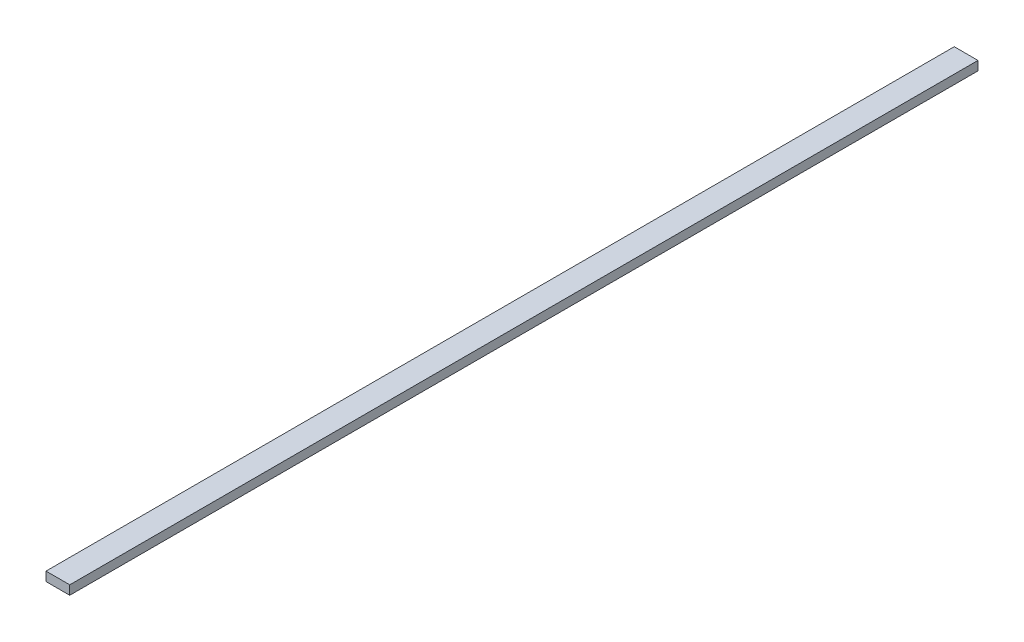
from build123d import *

# Parameters (mm, degrees)
SKETCH1_W           = 18.3
SKETCH1_H           = 7
BOSS_EXTRUDE1_DEPTH = 350


with BuildPart() as part:
    # Sketch1 → Boss-Extrude1 (new body, symmetric)
    with BuildSketch(Plane.XY):
        Rectangle(SKETCH1_W, SKETCH1_H)
    extrude(amount=BOSS_EXTRUDE1_DEPTH, both=True)


solid = part.part
